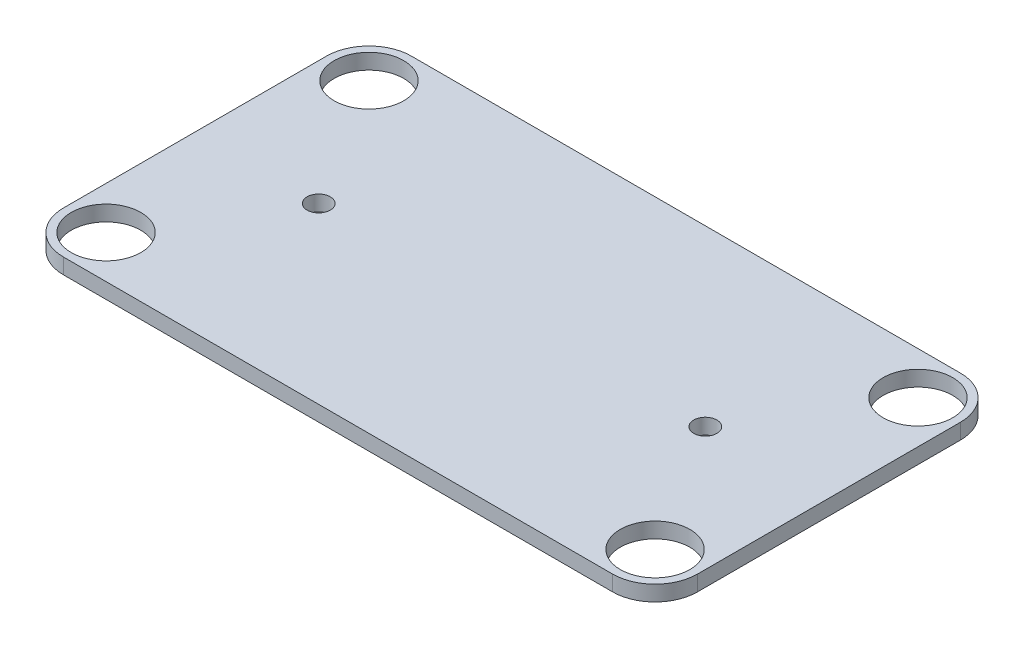
from build123d import *

# Parameters (mm, degrees)
ESQUISSE1_W        = 82
ESQUISSE1_H        = 45
ESQUISSE1_R        = 4.5
ESQUISSE1_R_2      = 1.5
BOSS_EXTRU_1_DEPTH = 2
CONG_1_R           = 5.5


with BuildPart() as part:
    # Esquisse1 → Boss.-Extru.1 (new body)
    with BuildSketch(Plane(origin=(0, 0, 0), x_dir=(1, 0, 0), z_dir=(0, 1, 0))):
        Rectangle(ESQUISSE1_W, ESQUISSE1_H)
        with Locations((-35.5, 17)):
            Circle(ESQUISSE1_R, mode=Mode.SUBTRACT)
        with Locations((35.5, 17)):
            Circle(ESQUISSE1_R, mode=Mode.SUBTRACT)
        with Locations((35.5, -17)):
            Circle(ESQUISSE1_R, mode=Mode.SUBTRACT)
        with Locations((-35.5, -17)):
            Circle(ESQUISSE1_R, mode=Mode.SUBTRACT)
        with Locations((-25, 0)):
            Circle(ESQUISSE1_R_2, mode=Mode.SUBTRACT)
        with Locations((25, 0)):
            Circle(ESQUISSE1_R_2, mode=Mode.SUBTRACT)
    extrude(amount=BOSS_EXTRU_1_DEPTH)

    # Congé1
    cong_1_edges = [part.edges().sort_by_distance(p)[0] for p in [
        (-41, 1, -22.5),
        (41, 1, -22.5),
        (41, 1, 22.5),
        (-41, 1, 22.5),
    ]]
    fillet(cong_1_edges, radius=CONG_1_R)


solid = part.part
